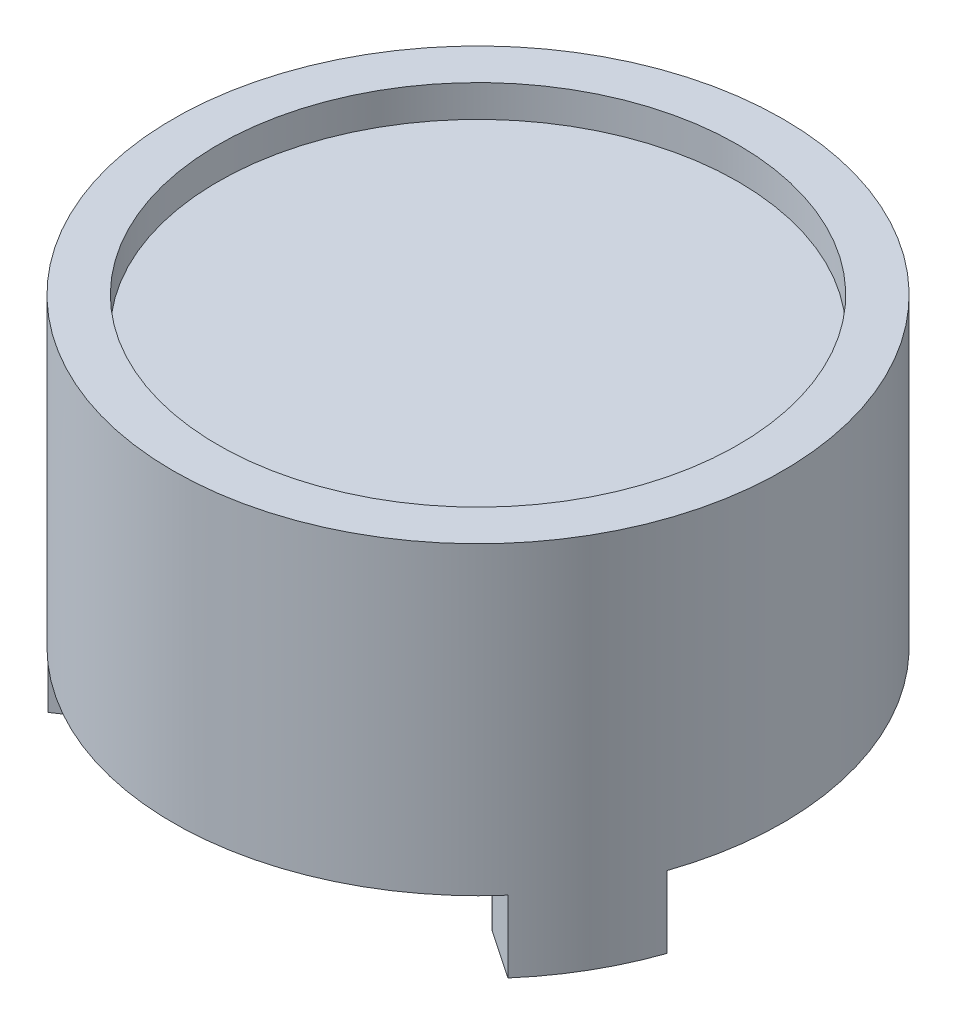
from build123d import *
from build123d.topology import SkipClean

# Parameters (mm, degrees)
TOOTH_DEPTH       = 4
THREE_TEETH_COUNT = 3
FILLET1_R         = 0.254


with BuildPart() as part:
    # Sketch4 → Revolve1 (revolve)
    with BuildSketch(Plane.XY, mode=Mode.PRIVATE) as revolve1_sk:
        Polygon((0, 15.222), (14.5, 15.222), (14.5, 17), (17, 17), (17, 0), (13.5, 0), (13.5, 1), (14.5, 1), (14.5, 2.522), (0, 2.522), align=None)
    revolve(revolve1_sk.sketch.rotate(Axis((0, 0, 0), (0, 1, 0)), 90), axis=Axis((0, 0, 0), (0, 1, 0)))

    # Sketch3 → Tooth (add)
    with SkipClean():  # the faces are left unmerged after this step: merging them gives an invalid solid
        with BuildSketch(Plane(origin=(0, 0, 0), x_dir=(1, 0, 0), z_dir=(0, 1, 0))):
            with BuildLine():
                Line((-3.25, 16.686447), (-3, 13.162447))
                ThreePointArc((-3, 13.162447), (0, 13.5), (3, 13.162447))
                Line((3, 13.162447), (3.25, 16.686447))
                ThreePointArc((3.25, 16.686447), (0, 17), (-3.25, 16.686447))
            make_face()
        tooth = extrude(amount=-TOOTH_DEPTH)

    # Three Teeth: Tooth ×3 about axis
    with SkipClean():  # the faces are left unmerged after this step: merging them gives an invalid solid
        three_teeth_axis = Axis((0, 0, 0), (0, 1, 0))
        for i in range(1, THREE_TEETH_COUNT):
            add(tooth.rotate(three_teeth_axis, i * 360 / THREE_TEETH_COUNT))

    # Fillet1
    fillet1_edges = [part.edges().sort_by_distance(p)[0] for p in [
        (-12.899013, -2, 3.983147),
        (-9.899013, -2, 9.1793),
        (-3, -2, -13.162447),
        (3, -2, -13.162447),
        (12.899013, -2, 3.983147),
        (9.899013, -2, 9.1793),
    ]]
    fillet(fillet1_edges, radius=FILLET1_R)


solid = part.part
